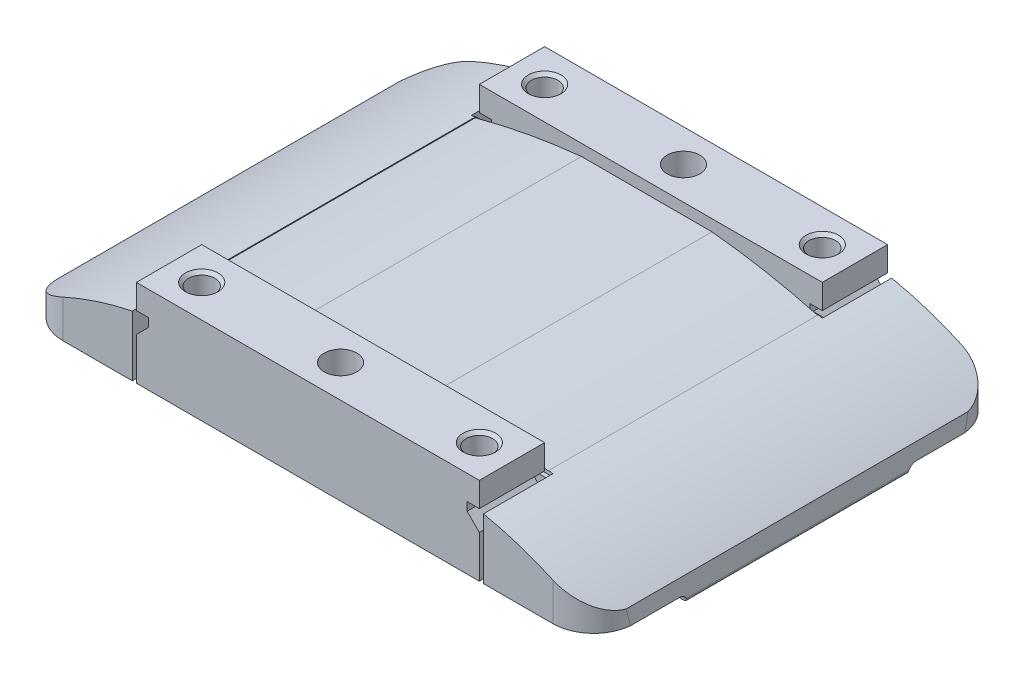
from build123d import *

# Parameters (mm, degrees)
BOSS_EXTRUDE1_DEPTH      = 25
BOSS_EXTRUDE1_DEPTH_BACK = 25
CUT_EXTRUDE1_DEPTH       = 17
CUT_EXTRUDE1_DEPTH_BACK  = 17
CUT_EXTRUDE2_DEPTH       = 8
CUT_EXTRUDE3_DEPTH       = 8
CUT_EXTRUDE4_DEPTH       = 21.5
CUT_EXTRUDE4_DEPTH_BACK  = 21.5
CUT_EXTRUDE5_DEPTH       = 35
CUT_EXTRUDE5_DEPTH_BACK  = 35
CUT_EXTRUDE6_DEPTH       = 29
CUT_EXTRUDE6_DEPTH_BACK  = 29
SKETCH7_W                = 107.768014059
SKETCH7_H                = 69.938488576


with BuildPart() as part:
    # Sketch1 → Boss-Extrude1 (new, two sides: drawn at the far end of the back side and taken through both)
    with BuildSketch(Plane.XY.offset(-BOSS_EXTRUDE1_DEPTH_BACK)):
        with BuildLine():
            Line((-34.5, 0.2), (-31.366025404, 0.2))
            Line((-31.366025404, 0.2), (-30.5, 0.7))
            Line((-30.5, 0.7), (-21, 0.7))
            Line((-21, 0.7), (-21, 0))
            Line((-21, 0), (21, 0))
            Line((21, 0), (21, 0.7))
            Line((21, 0.7), (30.5, 0.7))
            Line((30.5, 0.7), (31.366025404, 0.2))
            Line((31.366025404, 0.2), (34.5, 0.2))
            ThreePointArc((34.5, 0.2), (34.853553391, 0.346446609), (35, 0.7))
            Line((35, 0.7), (34.913292535, 3.182976936))
            ThreePointArc((34.913292535, 3.182976936), (28.216815843, 6.59637195), (21, 8.696761129))
            Line((21, 8.696761129), (21, 11.9))
            Line((21, 11.9), (-21, 11.9))
            Line((-21, 11.9), (-21, 8.696761129))
            ThreePointArc((-21, 8.696761129), (-28.216815843, 6.59637195), (-34.913292535, 3.182976936))
            Line((-34.913292535, 3.182976936), (-35, 0.7))
            ThreePointArc((-35, 0.7), (-34.853553391, 0.346446609), (-34.5, 0.2))
        make_face()
    extrude(amount=BOSS_EXTRUDE1_DEPTH + BOSS_EXTRUDE1_DEPTH_BACK)

    # Sketch2 → Cut-Extrude1 (cut, two sides: drawn at the far end of the back side and taken through both)
    with BuildSketch(Plane.XY.offset(-CUT_EXTRUDE1_DEPTH_BACK)):
        with BuildLine():
            Line((21, 8.594559394), (21, 30))
            Line((21, 30), (-21, 30))
            Line((-21, 30), (-21, 8.594559394))
            ThreePointArc((-21, 8.594559394), (0, 11.4), (21, 8.594559394))
        make_face()
    extrude(amount=CUT_EXTRUDE1_DEPTH + CUT_EXTRUDE1_DEPTH_BACK, mode=Mode.SUBTRACT)

    # Sketch3 → Cut-Extrude2 (cut)
    with BuildSketch(Plane.XY.offset(25)):
        Polygon((-21.5, -3), (-21, -3), (-21, 6.37), (-19.5, 7.87), (-19.5, 8.9), (-21, 8.9), (-21, 11.9), (21, 11.9), (21, 8.9), (19.5, 8.9), (19.5, 7.87), (21, 6.37), (21, -3), (21.5, -3), (21.5, 16.9), (-21.5, 16.9), align=None)
    extrude(amount=-CUT_EXTRUDE2_DEPTH, mode=Mode.SUBTRACT)

    # Sketch4 → Cut-Extrude3 (cut)
    with BuildSketch(Plane.XY.offset(-25)):
        Polygon((-21.5, -3), (-21, -3), (-21, 6.37), (-19.5, 7.87), (-19.5, 8.9), (-21, 8.9), (-21, 11.9), (21, 11.9), (21, 8.9), (19.5, 8.9), (19.5, 7.87), (21, 6.37), (21, -3), (21.5, -3), (21.5, 16.9), (-21.5, 16.9), align=None)
    extrude(amount=CUT_EXTRUDE3_DEPTH, mode=Mode.SUBTRACT)

    # Sketch5 → Cut-Extrude4 (cut, two sides: drawn at the far end of the back side and taken through both)
    with BuildSketch(Plane(origin=(0, 0, 0), x_dir=(0, 0, -1), z_dir=(1, 0, 0)).offset(-CUT_EXTRUDE4_DEPTH_BACK)):
        Polygon((-17, 8.25), (-16.5, 8.25), (-16.5, 11), (16.5, 11), (16.5, 8.25), (17, 8.25), (17, 12), (-17, 12), align=None)
    extrude(amount=CUT_EXTRUDE4_DEPTH + CUT_EXTRUDE4_DEPTH_BACK, mode=Mode.SUBTRACT)

    # Sketch6 → Cut-Extrude5 (cut, two sides: drawn at the far end of the back side and taken through both)
    with BuildSketch(Plane(origin=(0, 0, 0), x_dir=(0, 0, -1), z_dir=(1, 0, 0)).offset(-CUT_EXTRUDE5_DEPTH_BACK)):
        with BuildLine():
            Line((-30, 1.2), (-30, -5))
            Line((-30, -5), (30, -5))
            Line((30, -5), (30, 1.2))
            Line((30, 1.2), (14.5, 1.2))
            ThreePointArc((14.5, 1.2), (13.792893219, 0.907106781), (13.5, 0.2))
            Line((13.5, 0.2), (13.5, -2))
            Line((13.5, -2), (-13.5, -2))
            Line((-13.5, -2), (-13.5, 0.2))
            ThreePointArc((-13.5, 0.2), (-13.792893219, 0.907106781), (-14.5, 1.2))
            Line((-14.5, 1.2), (-30, 1.2))
        make_face()
    extrude(amount=CUT_EXTRUDE5_DEPTH + CUT_EXTRUDE5_DEPTH_BACK, mode=Mode.SUBTRACT)

    # Sketch7 → Cut-Extrude6 (cut, two sides: drawn at the far end of the back side and taken through both)
    with BuildSketch(Plane(origin=(0, 0, 0), x_dir=(-1, 0, 0), z_dir=(0, 1, 0)).offset(-CUT_EXTRUDE6_DEPTH_BACK)):
        with Locations((-2.122144112, 2.214411248)):
            Rectangle(SKETCH7_W, SKETCH7_H)
        with BuildLine():
            Line((35, -20), (35, 20))
            ThreePointArc((35, 20), (33.535533906, 23.535533906), (30, 25))
            Line((30, 25), (-30, 25))
            ThreePointArc((-30, 25), (-33.535533906, 23.535533906), (-35, 20))
            Line((-35, 20), (-35, -20))
            ThreePointArc((-35, -20), (-33.535533906, -23.535533906), (-30, -25))
            Line((-30, -25), (30, -25))
            ThreePointArc((30, -25), (33.535533906, -23.535533906), (35, -20))
        make_face(mode=Mode.SUBTRACT)
    extrude(amount=CUT_EXTRUDE6_DEPTH + CUT_EXTRUDE6_DEPTH_BACK, mode=Mode.SUBTRACT)

    # Sketch8 → Cut-Revolve1 (revolve, cut)
    with BuildSketch(Plane.XY.offset(21)):
        Polygon((-17, 2.364115214), (-18.621, 3.3), (-18.621, 11.521), (-19, 11.9), (-17, 11.9), align=None)
    revolve(axis=Axis((-17, 11.9, 21), (0, -1, 0)), mode=Mode.SUBTRACT)

    # Sketch9 → Cut-Revolve2 (revolve, cut)
    with BuildSketch(Plane.XY.offset(-21)):
        Polygon((-17, 2.364115214), (-18.621, 3.3), (-18.621, 11.521), (-19, 11.9), (-17, 11.9), align=None)
    revolve(axis=Axis((-17, 11.9, -21), (0, -1, 0)), mode=Mode.SUBTRACT)

    # Sketch10 → Cut-Revolve3 (revolve, cut)
    with BuildSketch(Plane.XY.offset(-21)):
        Polygon((17, 2.364115214), (15.379, 3.3), (15.379, 11.521), (15, 11.9), (17, 11.9), align=None)
    revolve(axis=Axis((17, 11.9, -21), (0, -1, 0)), mode=Mode.SUBTRACT)

    # Sketch11 → Cut-Revolve4 (revolve, cut)
    with BuildSketch(Plane.XY.offset(21)):
        Polygon((17, 2.364115214), (15.379, 3.3), (15.379, 11.521), (15, 11.9), (17, 11.9), align=None)
    revolve(axis=Axis((17, 11.9, 21), (0, -1, 0)), mode=Mode.SUBTRACT)

    # Sketch12 → Cut-Revolve5 (revolve, cut)
    with BuildSketch(Plane.XY.offset(21)):
        Polygon((0, 4.745299462), (-2, 5.9), (-2, 11.9), (0, 11.9), align=None)
    revolve(axis=Axis((0, 11.9, 21), (0, -1, 0)), mode=Mode.SUBTRACT)

    # Sketch13 → Cut-Revolve6 (revolve, cut)
    with BuildSketch(Plane.XY.offset(-21)):
        Polygon((0, 4.745299462), (-2, 5.9), (-2, 11.9), (0, 11.9), align=None)
    revolve(axis=Axis((0, 11.9, -21), (0, -1, 0)), mode=Mode.SUBTRACT)


solid = part.part
